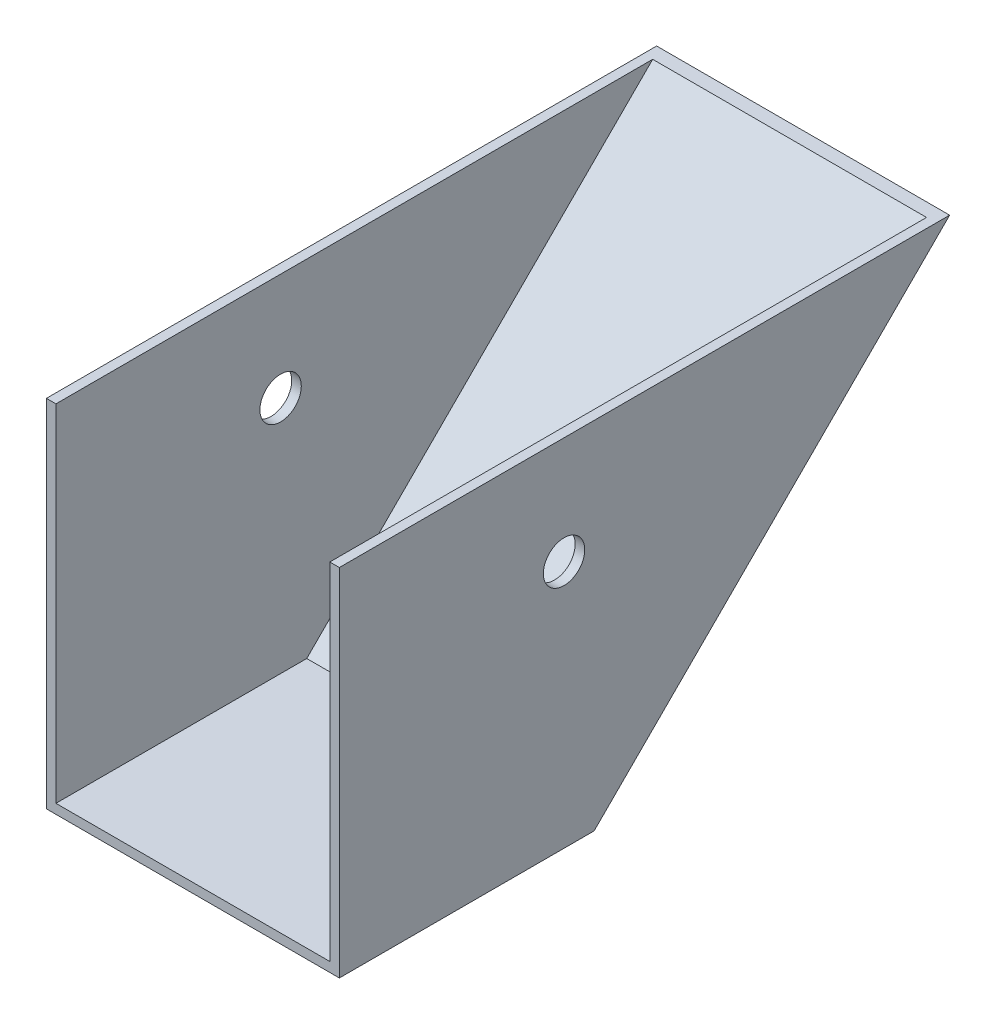
from build123d import *

# Parameters (mm, degrees)
SKETCH2_W           = 292.1
SKETCH2_H           = 635
BOSS_EXTRUDE1_DEPTH = 190.5
CUT_EXTRUDE2_DEPTH  = 381
SHELL1_T            = -9.525
SKETCH5_W           = 292.1
SKETCH5_H           = 635
CUT_EXTRUDE3_DEPTH  = 24.892
SKETCH6_R           = 20.6375
CUT_EXTRUDE4_DEPTH  = 514.096
SKETCH10_W          = 292.1
SKETCH10_H          = 610.108
CUT_EXTRUDE7_DEPTH  = 1.693333333


with BuildPart() as part:
    # Sketch2 → Boss-Extrude1 (new body, symmetric)
    with BuildSketch(Plane(origin=(0, 0, 0), x_dir=(1, 0, 0), z_dir=(0, 1, 0))):
        Rectangle(SKETCH2_W, SKETCH2_H)
    extrude(amount=BOSS_EXTRUDE1_DEPTH, both=True)

    # Sketch4 → Cut-Extrude2 (cut)
    with BuildSketch(Plane.ZY.offset(146.05)):
        Polygon((-317.5, 190.5), (63.5, -190.5), (-317.5, -190.5), align=None)
    extrude(amount=-CUT_EXTRUDE2_DEPTH, mode=Mode.SUBTRACT)

    # Shell1
    shell1_openings = [part.faces().sort_by_distance(p)[0] for p in [
        (0, 0, 317.5),
    ]]
    offset(amount=SHELL1_T, openings=shell1_openings, kind=Kind.INTERSECTION)

    # Sketch5 → Cut-Extrude3 (cut)
    with BuildSketch(Plane(origin=(0, 190.5, 0), x_dir=(1, 0, 0), z_dir=(0, 1, 0))):
        Rectangle(SKETCH5_W, SKETCH5_H)
    extrude(amount=-CUT_EXTRUDE3_DEPTH, mode=Mode.SUBTRACT)

    # Sketch6 → Cut-Extrude4 (cut)
    with BuildSketch(Plane.ZY.offset(146.05)):
        with Locations((93.517292524, 56.961208915)):
            Circle(SKETCH6_R)
    extrude(amount=-CUT_EXTRUDE4_DEPTH, mode=Mode.SUBTRACT)

    # Sketch10 → Cut-Extrude7 (cut)
    with BuildSketch(Plane(origin=(0, 165.608, 0), x_dir=(1, 0, 0), z_dir=(0, 1, 0))):
        with Locations((0, -12.446)):
            Rectangle(SKETCH10_W, SKETCH10_H)
    extrude(amount=-CUT_EXTRUDE7_DEPTH, mode=Mode.SUBTRACT)


solid = part.part
